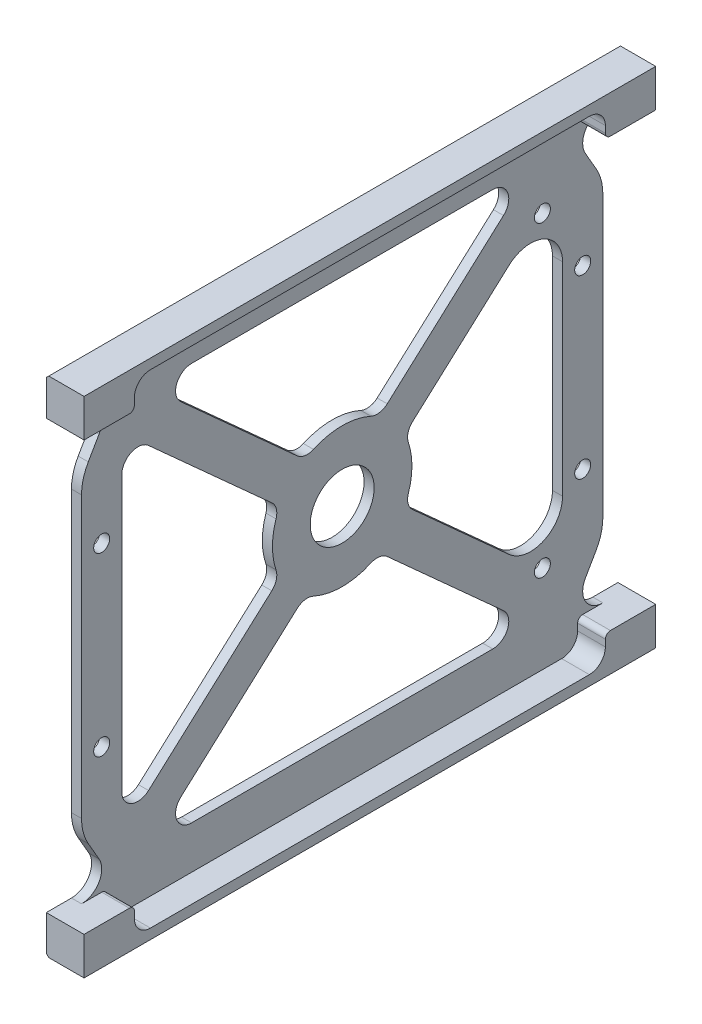
from build123d import *

# Parameters (mm, degrees)
BOSS_EXTRUDE1_DEPTH = 56.75
SKETCH2_W           = 5
SKETCH2_H           = 85
SKETCH2_R           = 1.5875
CUT_EXTRUDE1_DEPTH  = 2
SKETCH3_R           = 6.35
SKETCH3_R_2         = 1.5875
CUT_EXTRUDE2_DEPTH  = 3
CHAMFER1_SIZE       = 0.5
CUT_EXTRUDE3_DEPTH  = 5.5
CUT_EXTRUDE4_DEPTH  = 10


with BuildPart() as part:
    # Sketch1 → Boss-Extrude1 (new body, symmetric)
    with BuildSketch(Plane.XY):
        Polygon((0, 50), (0, -50), (7.5, -50), (7.5, -42.5), (2, -42.5), (2, 42.5), (7.5, 42.5), (7.5, 50), align=None)
    extrude(amount=BOSS_EXTRUDE1_DEPTH, both=True)

    # Sketch2 → Cut-Extrude1 (cut)
    with BuildSketch(Plane(origin=(2, 0, 0), x_dir=(0, 0, -1), z_dir=(1, 0, 0))):
        with Locations((-54.25, 0)):
            Rectangle(SKETCH2_W, SKETCH2_H)
        with Locations((54.25, 0)):
            Rectangle(SKETCH2_W, SKETCH2_H)
        with Locations((-47.75, 17.5)):
            Circle(SKETCH2_R)
        with Locations((-47.75, -17.5)):
            Circle(SKETCH2_R)
        with Locations((47.75, 17.5)):
            Circle(SKETCH2_R)
        with Locations((47.75, -17.5)):
            Circle(SKETCH2_R)
    extrude(amount=-CUT_EXTRUDE1_DEPTH, mode=Mode.SUBTRACT)

    # Sketch3 → Cut-Extrude2 (cut, through all)
    with BuildSketch(Plane(origin=(2, 0, 0), x_dir=(0, 0, -1), z_dir=(1, 0, 0))):
        Circle(SKETCH3_R)
        with Locations((39.75, 30.5)):
            Circle(SKETCH3_R_2)
        with Locations((39.75, -30.5)):
            Circle(SKETCH3_R_2)
        with BuildLine():
            Line((-29.899655804, -39.5), (29.899655804, -39.5))
            ThreePointArc((29.899655804, -39.5), (32.863003185, -37.464823364), (32.027336169, -33.968392001))
            Line((32.027336169, -33.968392001), (8.946350194, -13.129558949))
            ThreePointArc((8.946350194, -13.129558949), (7.399307524, -12.392275536), (5.701057458, -12.622220243))
            ThreePointArc((5.701057458, -12.622220243), (0, -13.85), (-5.701057458, -12.622220243))
            ThreePointArc((-5.701057458, -12.622220243), (-7.399307524, -12.392275536), (-8.946350194, -13.129558949))
            Line((-8.946350194, -13.129558949), (-32.027336169, -33.968392001))
            ThreePointArc((-32.027336169, -33.968392001), (-32.863003185, -37.464823364), (-29.899655804, -39.5))
        make_face()
        with BuildLine():
            Line((-43.75, -27.303546383), (-43.75, 27.303546383))
            ThreePointArc((-43.75, 27.303546383), (-41.864426198, 30.204926241), (-38.447319635, 29.660154382))
            Line((-38.447319635, 29.660154382), (-13.972366805, 7.562768399))
            ThreePointArc((-13.972366805, 7.562768399), (-13.081370721, 6.098851109), (-13.137175803, 4.386013216))
            ThreePointArc((-13.137175803, 4.386013216), (-13.85, 0), (-13.137175803, -4.386013216))
            ThreePointArc((-13.137175803, -4.386013216), (-13.081370721, -6.098851109), (-13.972366805, -7.562768399))
            Line((-13.972366805, -7.562768399), (-38.447319635, -29.660154382))
            ThreePointArc((-38.447319635, -29.660154382), (-41.864426198, -30.204926241), (-43.75, -27.303546383))
        make_face()
        with BuildLine():
            Line((-29.899655804, 39.5), (29.899655804, 39.5))
            ThreePointArc((29.899655804, 39.5), (32.863003185, 37.464823364), (32.027336169, 33.968392001))
            Line((32.027336169, 33.968392001), (8.946350194, 13.129558949))
            ThreePointArc((8.946350194, 13.129558949), (7.399307524, 12.392275536), (5.701057458, 12.622220243))
            ThreePointArc((5.701057458, 12.622220243), (0, 13.85), (-5.701057458, 12.622220243))
            ThreePointArc((-5.701057458, 12.622220243), (-7.399307524, 12.392275536), (-8.946350194, 13.129558949))
            Line((-8.946350194, 13.129558949), (-32.027336169, 33.968392001))
            ThreePointArc((-32.027336169, 33.968392001), (-32.863003185, 37.464823364), (-29.899655804, 39.5))
        make_face()
        with BuildLine():
            Line((43.75, -20.159375539), (43.75, 20.159375539))
            ThreePointArc((43.75, 20.159375539), (39.978852396, 25.962135255), (33.144639269, 24.872591538))
            Line((33.144639269, 24.872591538), (13.972366805, 7.562768399))
            ThreePointArc((13.972366805, 7.562768399), (13.081370721, 6.098851109), (13.137175803, 4.386013216))
            ThreePointArc((13.137175803, 4.386013216), (13.85, 0), (13.137175803, -4.386013216))
            ThreePointArc((13.137175803, -4.386013216), (13.081370721, -6.098851109), (13.972366805, -7.562768399))
            Line((13.972366805, -7.562768399), (33.144639269, -24.872591538))
            ThreePointArc((33.144639269, -24.872591538), (39.978852396, -25.962135255), (43.75, -20.159375539))
        make_face()
    extrude(amount=-CUT_EXTRUDE2_DEPTH, mode=Mode.SUBTRACT)

    # Chamfer1
    chamfer1_edges = [part.edges().sort_by_distance(p)[0] for p in [
        (0, -50, 0),
        (0, 50, 0),
    ]]
    chamfer(chamfer1_edges, length=CHAMFER1_SIZE)

    # Sketch4 → Cut-Extrude3 (cut)
    with BuildSketch(Plane(origin=(7.5, 0, 0), x_dir=(0, 0, -1), z_dir=(1, 0, 0))):
        with BuildLine():
            Line((43.575, -48), (-43.575, -48))
            ThreePointArc((-43.575, -48), (-45.82006403, -47.07006403), (-46.75, -44.825))
            Line((-46.75, -44.825), (-46.75, -43.5))
            ThreePointArc((-46.75, -43.5), (-47.042893219, -42.792893219), (-47.75, -42.5))
            Line((-47.75, -42.5), (47.75, -42.5))
            ThreePointArc((47.75, -42.5), (47.042893219, -42.792893219), (46.75, -43.5))
            Line((46.75, -43.5), (46.75, -44.825))
            ThreePointArc((46.75, -44.825), (45.82006403, -47.07006403), (43.575, -48))
        make_face()
        with BuildLine():
            Line((-46.75, 44.825), (-46.75, 43.5))
            ThreePointArc((-46.75, 43.5), (-47.042893219, 42.792893219), (-47.75, 42.5))
            Line((-47.75, 42.5), (47.75, 42.5))
            ThreePointArc((47.75, 42.5), (47.042893219, 42.792893219), (46.75, 43.5))
            Line((46.75, 43.5), (46.75, 44.825))
            ThreePointArc((46.75, 44.825), (45.82006403, 47.07006403), (43.575, 48))
            Line((43.575, 48), (-43.575, 48))
            ThreePointArc((-43.575, 48), (-45.82006403, 47.07006403), (-46.75, 44.825))
        make_face()
    extrude(amount=-CUT_EXTRUDE3_DEPTH, mode=Mode.SUBTRACT)

    # Sketch5 → Cut-Extrude4 (cut)
    with BuildSketch(Plane.ZY):
        with BuildLine():
            ThreePointArc((-51.75, 27.820508076), (-51.409258263, 30.408698527), (-50.410254038, 32.820508076))
            Line((-50.410254038, 32.820508076), (-48.285898385, 36.5))
            ThreePointArc((-48.285898385, 36.5), (-48.285898385, 40.5), (-51.75, 42.5))
            Line((-51.75, 42.5), (-51.75, 27.820508076))
        make_face()
        with BuildLine():
            ThreePointArc((-50.410254038, -32.820508076), (-51.409258263, -30.408698527), (-51.75, -27.820508076))
            Line((-51.75, -27.820508076), (-51.75, -42.5))
            ThreePointArc((-51.75, -42.5), (-48.285898385, -40.5), (-48.285898385, -36.5))
            Line((-48.285898385, -36.5), (-50.410254038, -32.820508076))
        make_face()
    cut_extrude4 = extrude(amount=-CUT_EXTRUDE4_DEPTH, mode=Mode.SUBTRACT)

    # Mirror1: Cut-Extrude4 across plane
    add(cut_extrude4.mirror(Plane.XY), mode=Mode.SUBTRACT)


solid = part.part
